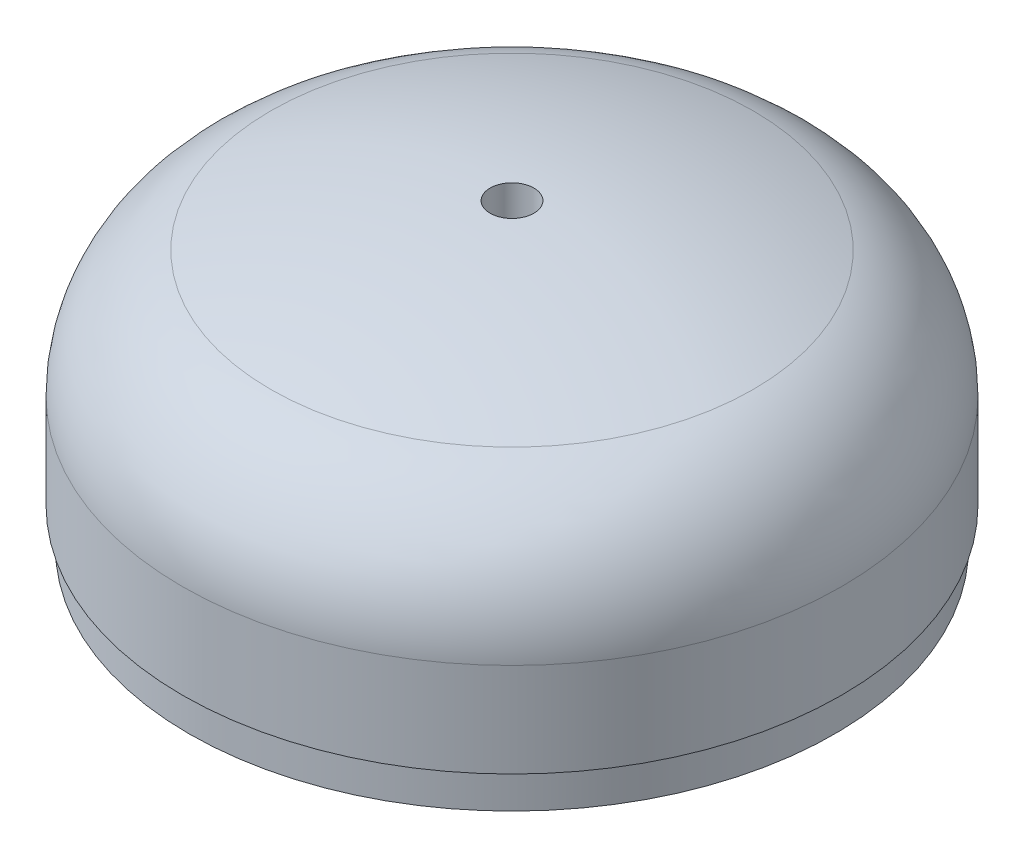
from build123d import *


with BuildPart() as part:
    # Sketch1 → Revolve2 (revolve)
    with BuildSketch(Plane.XY):
        with BuildLine():
            Line((-63.5, 7.0880256), (-63.5, 25.209576395))
            ThreePointArc((-63.5, 25.209576395), (-58.831621889, 40.085351805), (-46.500676471, 49.626328344))
            ThreePointArc((-46.500676471, 49.626328344), (-25.692788323, 55.467905735), (-4.2164, 57.8880256))
            Line((-4.2164, 57.8880256), (-4.2164, 50.899373851))
            ThreePointArc((-4.2164, 50.899373851), (-24.461267699, 48.591399426), (-44.076470588, 43.075492455))
            ThreePointArc((-44.076470588, 43.075492455), (-53.099113577, 36.09429011), (-56.515, 25.209576395))
            Line((-56.515, 25.209576395), (-59.840452163, 6.35))
            Line((-59.840452163, 6.35), (-59.840452163, 0))
            Line((-59.840452163, 0), (-62.221702163, 0))
            Line((-62.221702163, 0), (-62.221702163, 6.35))
            Line((-62.221702163, 6.35), (-63.5, 7.0880256))
        make_face()
    revolve(axis=Axis((0, 127.060987048, 0), (0, -1, 0)))


solid = part.part
